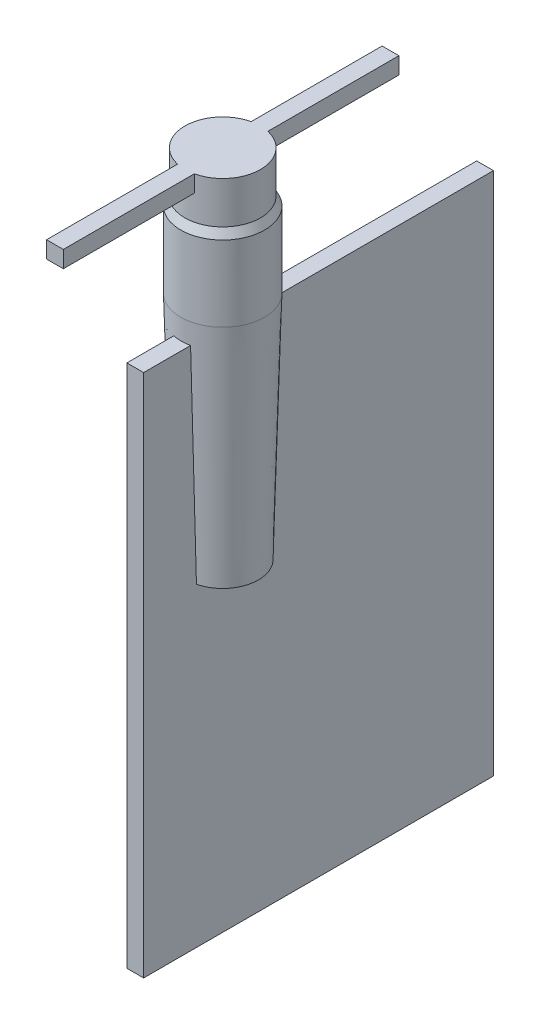
from build123d import *

# Parameters (mm, degrees)
SKETCH_8_R       = 450
EXTRUDE_3_DEPTH  = 500
SKETCH_20_R      = 425
SKETCH_22_W      = 4170
SKETCH_22_H      = 6250
EXTRUDE_9_DEPTH  = 100
SKETCH_25_W      = 200
SKETCH_25_H      = 4000
EXTRUDE_12_DEPTH = 200


with BuildPart() as part:
    # 草图8 → 凸台-拉伸3 (new body)
    with BuildSketch(Plane(origin=(0, 0, 0), x_dir=(1, 0, 0), z_dir=(0, 1, 0))):
        with Locations(Location((0, 0, 0), (0, 0, 270))):
            Circle(SKETCH_8_R)
    extrude(amount=-EXTRUDE_3_DEPTH)

    # 草图19 → 旋转1 (revolve)
    with BuildSketch(Plane(origin=(0, 0, 0), x_dir=(0, 0, -1), z_dir=(1, 0, 0))):
        Polygon((450, -500), (500, -600), (500, -1500), (0, -1500), (0, -500), align=None)
    revolve(axis=Axis((0, -1500, 0), (0, 1, 0)))

    # 草图20 → section 1 of loft_2
    with BuildSketch(Plane(origin=(0, -4250, 0), x_dir=(-1, 0, 0), z_dir=(0, -1, 0)), mode=Mode.PRIVATE) as loft_2_s1:
        Circle(SKETCH_20_R)
    # loft up to a face of the part (loft_2)
    loft([Face(Wire([part.edges().sort_by_distance((364.484313711, -1500, 342.273552964))[0]])), loft_2_s1.sketch])

    # 草图22 → 凸台-拉伸9 (add, symmetric)
    with BuildSketch(Plane(origin=(0, 0, 0), x_dir=(0, 0, -1), z_dir=(1, 0, 0))):
        with Locations((1042.5, -4875)):
            Rectangle(SKETCH_22_W, SKETCH_22_H)
    extrude(amount=EXTRUDE_9_DEPTH, both=True)

    # 草图25 → 凸台-拉伸12 (add)
    with BuildSketch(Plane(origin=(0, 0, 0), x_dir=(1, 0, 0), z_dir=(0, 1, 0))):
        Rectangle(SKETCH_25_W, SKETCH_25_H)
    extrude(amount=-EXTRUDE_12_DEPTH)


solid = part.part
